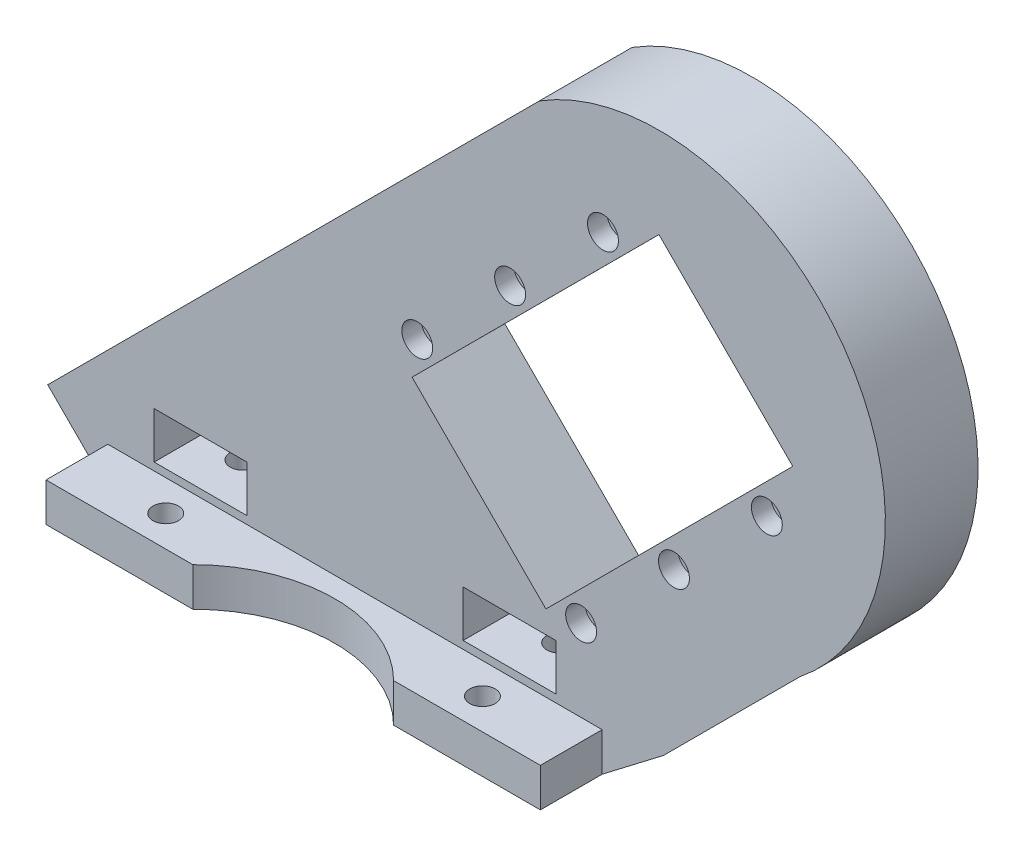
from build123d import *

# Parameters (mm, degrees)
BOSS_EXTRUDE2_DEPTH     = 12
CUT_EXTRUDE1_DEPTH      = 13
SKETCH3_R               = 1.25
CUT_EXTRUDE2_DEPTH      = 13
SKETCH5_R               = 1.65
CUT_EXTRUDE3_DEPTH      = 6
SKETCH6_W               = 12
SKETCH6_H               = 6
CUT_EXTRUDE4_DEPTH      = 13
SKETCH8_W               = 64
SKETCH8_H               = 8
BOSS_EXTRUDE3_DEPTH     = 5
SKETCH9_R               = 1.65
CUT_EXTRUDE5_DEPTH      = 5
SKETCH10_R              = 2
CUT_EXTRUDE6_DEPTH      = 2.5
CUT_EXTRUDE7_DEPTH      = 71.896039473
CUT_EXTRUDE7_DEPTH_BACK = 10


with BuildPart() as part:
    # Sketch1 → Boss-Extrude2 (new body)
    with BuildSketch(Plane.XY):
        with BuildLine():
            Line((0, 0), (64, 0))
            Line((64, 0), (71.941945847, 6.076635266))
            Line((71.941945847, 6.076635266), (89.619615377, 23.754304796))
            ThreePointArc((89.619615377, 23.754304796), (95.283552654, 63.552389681), (55.861435714, 71.4177849))
            Line((55.861435714, 71.4177849), (-7.778174593, 7.778174593))
            Line((-7.778174593, 7.778174593), (0, 0))
        make_face()
    extrude(amount=BOSS_EXTRUDE2_DEPTH)

    # Sketch2 → Cut-Extrude1 (cut, through all)
    with BuildSketch(Plane.XY.offset(12)):
        Polygon((56.718479601, 14.889386235), (39.391727984, 32.210866495), (71.348091567, 64.176955192), (88.674843183, 46.855474932), align=None)
    extrude(amount=-CUT_EXTRUDE1_DEPTH, mode=Mode.SUBTRACT)

    # Sketch3 → Cut-Extrude2 (cut, through all)
    with BuildSketch(Plane.XY.offset(12)):
        with Locations((85.317188693, 39.60711951)):
            Circle(SKETCH3_R)
        with Locations((73.296373413, 27.58630423)):
            Circle(SKETCH3_R)
        with Locations((61.275558133, 15.565488949)):
            Circle(SKETCH3_R)
        with Locations((64.100758142, 60.817095339)):
            Circle(SKETCH3_R)
        with Locations((52.083601094, 48.792622939)):
            Circle(SKETCH3_R)
        with Locations((40.066444047, 36.76815054)):
            Circle(SKETCH3_R)
    extrude(amount=-CUT_EXTRUDE2_DEPTH, mode=Mode.SUBTRACT)

    # Sketch5 → Cut-Extrude3 (cut)
    with BuildSketch(Plane.XZ):
        with Locations((11.5, 6)):
            Circle(SKETCH5_R)
        with Locations((52.5, 6)):
            Circle(SKETCH5_R)
    extrude(amount=-CUT_EXTRUDE3_DEPTH, mode=Mode.SUBTRACT)

    # Sketch6 → Cut-Extrude4 (cut, through all)
    with BuildSketch(Plane.XY.offset(12)):
        with Locations((12, 9)):
            Rectangle(SKETCH6_W, SKETCH6_H)
        with Locations((52, 9)):
            Rectangle(SKETCH6_W, SKETCH6_H)
    extrude(amount=-CUT_EXTRUDE4_DEPTH, mode=Mode.SUBTRACT)

    # Sketch8 → Boss-Extrude3 (add)
    with BuildSketch(Plane.XZ):
        with Locations((32, 16)):
            Rectangle(SKETCH8_W, SKETCH8_H)
    extrude(amount=-BOSS_EXTRUDE3_DEPTH)

    # Sketch9 → Cut-Extrude5 (cut)
    with BuildSketch(Plane.XZ):
        with Locations((11.5, 16)):
            Circle(SKETCH9_R)
        with Locations((52.5, 16)):
            Circle(SKETCH9_R)
    extrude(amount=-CUT_EXTRUDE5_DEPTH, mode=Mode.SUBTRACT)

    # Sketch10 → Cut-Extrude6 (cut)
    with BuildSketch(Plane.XY.offset(12)):
        with Locations((85.317188693, 39.60711951)):
            Circle(SKETCH10_R)
        with Locations((73.296373413, 27.58630423)):
            Circle(SKETCH10_R)
        with Locations((61.275558133, 15.565488949)):
            Circle(SKETCH10_R)
        with Locations((40.060741262, 36.78030582)):
            Circle(SKETCH10_R)
        with Locations((52.081556543, 48.8011211)):
            Circle(SKETCH10_R)
        with Locations((64.102371823, 60.82193638)):
            Circle(SKETCH10_R)
    extrude(amount=-CUT_EXTRUDE6_DEPTH, mode=Mode.SUBTRACT)

    # Sketch11 → Cut-Extrude7 (cut, two sides)
    with BuildSketch(Plane(origin=(0, 5, 0), x_dir=(1, 0, 0), z_dir=(0, 1, 0))) as cut_extrude7_sk:
        with BuildLine():
            ThreePointArc((45, -20), (32, -14.615223689), (19, -20))
            Line((19, -20), (45, -20))
        make_face()
    extrude(amount=CUT_EXTRUDE7_DEPTH, mode=Mode.SUBTRACT)
    extrude(cut_extrude7_sk.sketch, amount=-CUT_EXTRUDE7_DEPTH_BACK, mode=Mode.SUBTRACT)


solid = part.part
